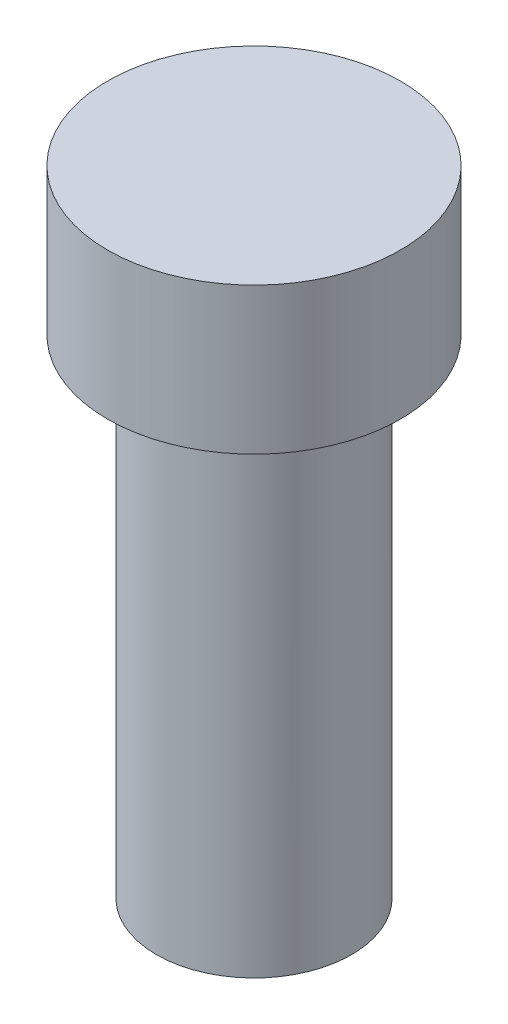
from build123d import *

# Parameters (mm, degrees)
SKETCH1_R           = 3
BOSS_EXTRUDE1_DEPTH = 3
SKETCH2_R           = 2
BOSS_EXTRUDE2_DEPTH = 10


with BuildPart() as part:
    # Sketch1 → Boss-Extrude1 (new body)
    with BuildSketch(Plane(origin=(0, 0, 0), x_dir=(1, 0, 0), z_dir=(0, 1, 0))):
        Circle(SKETCH1_R)
    extrude(amount=BOSS_EXTRUDE1_DEPTH)

    # Sketch2 → Boss-Extrude2 (add)
    with BuildSketch(Plane.XZ):
        Circle(SKETCH2_R)
    extrude(amount=BOSS_EXTRUDE2_DEPTH)


solid = part.part
